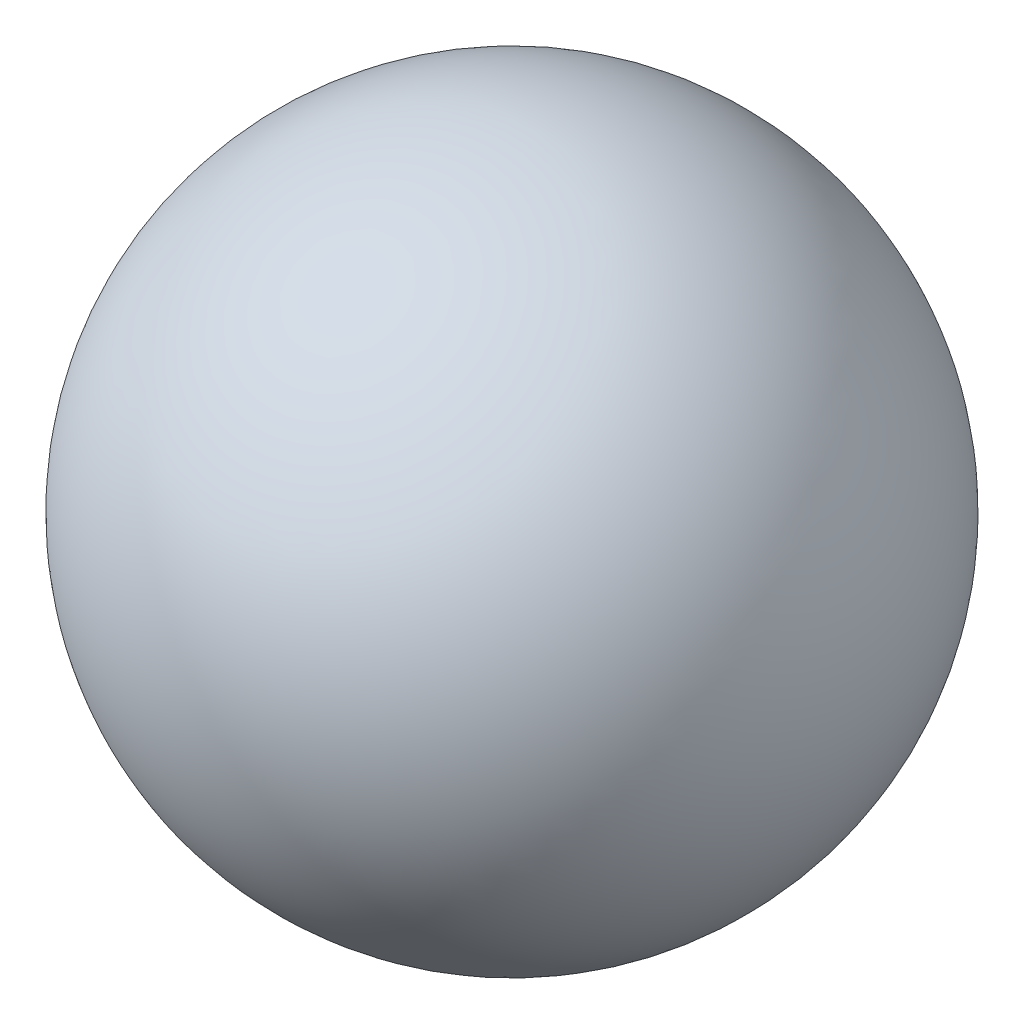
from build123d import *


with BuildPart() as part:
    # Sketch2 → Revolve1 (revolve)
    with BuildSketch(Plane(origin=(0, 0, 0), x_dir=(1, 0, 0), z_dir=(0, 1, 0))):
        with BuildLine():
            Line((0, 183.8), (0, -183.8))
            ThreePointArc((0, -183.8), (183.8, 0), (0, 183.8))
        make_face()
    revolve(axis=Axis((0, 0, -183.8), (0, 0, 1)))


solid = part.part
